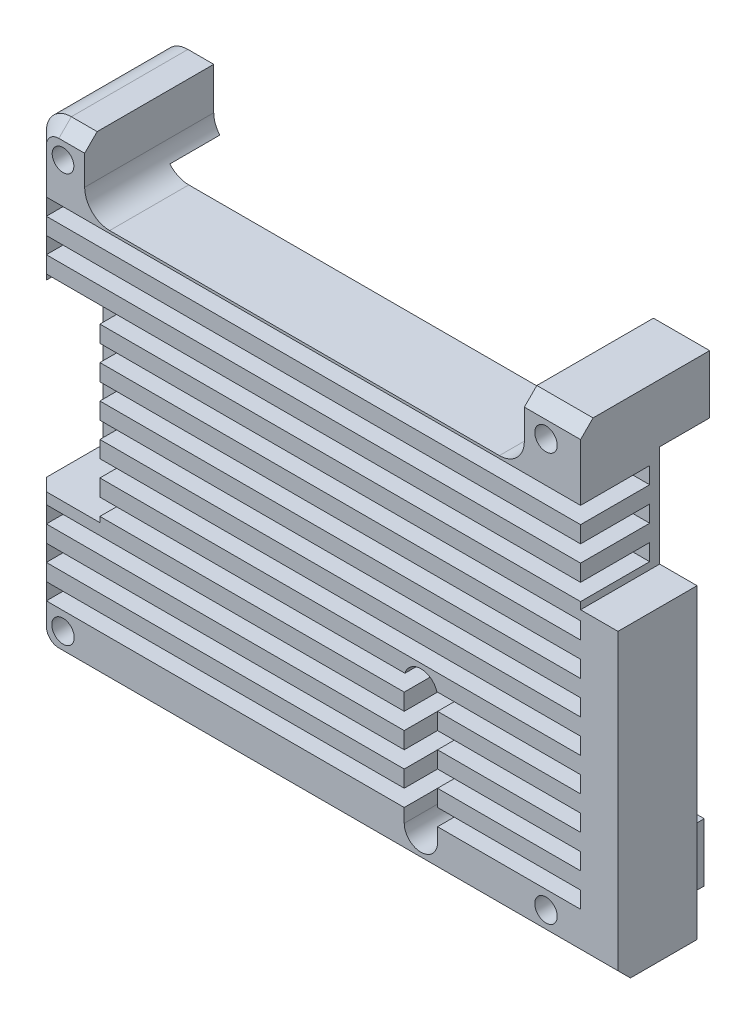
from build123d import *

# Parameters (mm, degrees)
SKETCH1_R           = 1.35
SKETCH1_R_2         = 1.3
BOSS_EXTRUDE1_DEPTH = 15.5
CUT_EXTRUDE1_DEPTH  = 6
FILLET1_R           = 3
CHAMFER1_SIZE       = 1.5
SKETCH3_W           = 7.93
SKETCH3_H           = 22
CUT_EXTRUDE2_DEPTH  = 8.3
SKETCH4_W           = 64.15
SKETCH4_H           = 2
CUT_EXTRUDE3_DEPTH  = 8.3


with BuildPart() as part:
    # Sketch1 → Boss-Extrude1 (new body)
    with BuildSketch(Plane.XY):
        with BuildLine():
            Line((-36.4, 19.96), (-36.4, 28))
            Line((-36.4, 28), (-39.5, 28))
            ThreePointArc((-39.5, 28), (-41.621320344, 27.121320344), (-42.5, 25))
            Line((-42.5, 25), (-42.5, -25))
            ThreePointArc((-42.5, -25), (-41.621320344, -27.121320344), (-39.5, -28))
            Line((-39.5, -28), (27.64, -28))
            Line((27.64, -28), (27.64, 8.8))
            Line((27.64, 8.8), (23.15, 8.8))
            Line((23.15, 8.8), (23.15, 28))
            Line((23.15, 28), (16.4, 28))
            Line((16.4, 28), (16.4, 21.51))
            Line((16.4, 21.51), (22.004438923, 21.51))
            Line((22.004438923, 21.51), (22.004438923, 15.51))
            Line((22.004438923, 15.51), (16.004438923, 15.51))
            Line((16.004438923, 15.51), (16.004438923, 19.96))
            Line((16.004438923, 19.96), (-36.4, 19.96))
        make_face()
        with Locations((-39, -24.5)):
            Circle(SKETCH1_R, mode=Mode.SUBTRACT)
        with Locations((19, -24.5)):
            Circle(SKETCH1_R, mode=Mode.SUBTRACT)
        with BuildLine():
            ThreePointArc((1.975, -8.92), (3.975, -6.92), (5.975, -8.92))
            Line((5.975, -8.92), (5.975, -24))
            ThreePointArc((5.975, -24), (3.975, -26), (1.975, -24))
            Line((1.975, -24), (1.975, -8.92))
        make_face(mode=Mode.SUBTRACT)
        with BuildLine():
            ThreePointArc((-40.535, 7.54), (-38.535, 9.54), (-36.535, 7.54))
            Line((-36.535, 7.54), (-36.535, -7.54))
            ThreePointArc((-36.535, -7.54), (-38.535, -9.54), (-40.535, -7.54))
            Line((-40.535, -7.54), (-40.535, 7.54))
        make_face(mode=Mode.SUBTRACT)
        with Locations((-39, 24.5)):
            Circle(SKETCH1_R_2, mode=Mode.SUBTRACT)
        with Locations((19, 24.5)):
            Circle(SKETCH1_R, mode=Mode.SUBTRACT)
        Polygon((22.004438923, 21.51), (16.4, 21.51), (16.4, 19.96), (16.004438923, 19.96), (16.004438923, 15.51), (22.004438923, 15.51), align=None)
    extrude(amount=BOSS_EXTRUDE1_DEPTH)

    # Sketch2 → Cut-Extrude1 (cut)
    with BuildSketch(Plane(origin=(0, 0, 0), x_dir=(-1, 0, 0), z_dir=(0, 0, -1))):
        Polygon((-16.4, 19.96), (-16.4, 21), (-23.15, 21), (-23.15, 8.8), (-27.64, 8.8), (-27.64, -28), (-22.5, -28), (-22.5, -21), (-15.5, -21), (-15.5, -28), (35.5, -28), (35.5, -21), (42.5, -21), (42.5, 21), (36.4, 21), (36.4, 19.96), align=None)
        with BuildLine():
            Line((-1.975, -8.92), (-1.975, -24))
            ThreePointArc((-1.975, -24), (-3.975, -26), (-5.975, -24))
            Line((-5.975, -24), (-5.975, -8.92))
            ThreePointArc((-5.975, -8.92), (-3.975, -6.92), (-1.975, -8.92))
        make_face(mode=Mode.SUBTRACT)
        with BuildLine():
            Line((40.535, 7.54), (40.535, -7.54))
            ThreePointArc((40.535, -7.54), (38.535, -9.54), (36.535, -7.54))
            Line((36.535, -7.54), (36.535, 7.54))
            ThreePointArc((36.535, 7.54), (38.535, 9.54), (40.535, 7.54))
        make_face(mode=Mode.SUBTRACT)
    extrude(amount=-CUT_EXTRUDE1_DEPTH, mode=Mode.SUBTRACT)

    # Fillet1
    fillet1_edges = [part.edges().sort_by_distance(p)[0] for p in [
        (-36.4, 19.96, 10.75),
        (16.4, 19.96, 10.75),
    ]]
    fillet(fillet1_edges, radius=FILLET1_R)

    # Chamfer1
    chamfer1_edges = [part.edges().sort_by_distance(p)[0] for p in [
        (-37.95, 28, 15.5),
        (-41.621320344, 27.121320344, 15.5),
        (-42.5, 0, 15.5),
        (-41.621320344, -27.121320344, 15.5),
        (-5.93, -28, 15.5),
        (19.775, 28, 15.5),
    ]]
    chamfer(chamfer1_edges, length=CHAMFER1_SIZE)

    # Sketch3 → Cut-Extrude2 (cut)
    with BuildSketch(Plane.XY.offset(15.5)):
        with Locations((-38.535, 0)):
            Rectangle(SKETCH3_W, SKETCH3_H)
    extrude(amount=-CUT_EXTRUDE2_DEPTH, mode=Mode.SUBTRACT)

    # Sketch4 → Cut-Extrude3 (cut)
    with BuildSketch(Plane.XY.offset(15.5)):
        with Locations((-8.925, 18.65)):
            Rectangle(SKETCH4_W, SKETCH4_H)
        with Locations((-8.925, 14.65)):
            Rectangle(SKETCH4_W, SKETCH4_H)
        with Locations((-8.925, 10.65)):
            Rectangle(SKETCH4_W, SKETCH4_H)
        with Locations((-8.925, 6.65)):
            Rectangle(SKETCH4_W, SKETCH4_H)
        with Locations((-8.925, 2.65)):
            Rectangle(SKETCH4_W, SKETCH4_H)
        with Locations((-8.925, -1.35)):
            Rectangle(SKETCH4_W, SKETCH4_H)
        with Locations((-8.925, -5.35)):
            Rectangle(SKETCH4_W, SKETCH4_H)
        with Locations((-8.925, -9.35)):
            Rectangle(SKETCH4_W, SKETCH4_H)
        with Locations((-8.925, -13.35)):
            Rectangle(SKETCH4_W, SKETCH4_H)
        with Locations((-8.925, -17.35)):
            Rectangle(SKETCH4_W, SKETCH4_H)
        with Locations((-8.925, -21.35)):
            Rectangle(SKETCH4_W, SKETCH4_H)
    extrude(amount=-CUT_EXTRUDE3_DEPTH, mode=Mode.SUBTRACT)


solid = part.part
